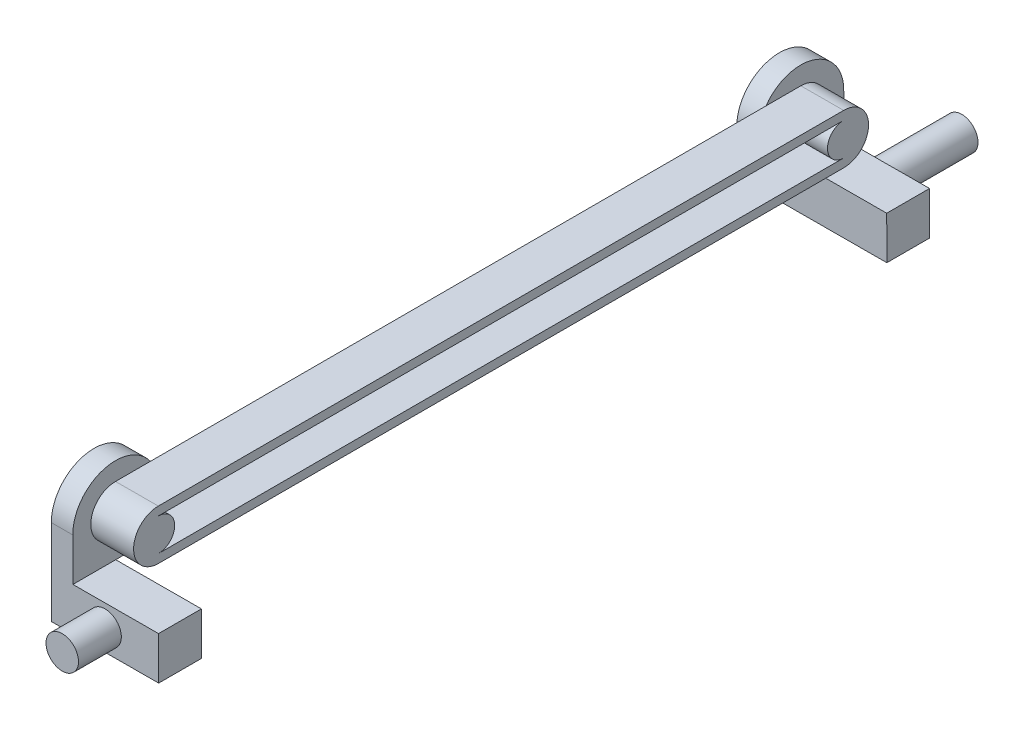
from build123d import *

# Parameters (mm, degrees)
SKETCH1_R           = 3.795
BOSS_EXTRUDE1_DEPTH = 10
BOSS_EXTRUDE2_DEPTH = 180
BOSS_EXTRUDE3_START = 10
SKETCH4_R           = 3.795
BOSS_EXTRUDE3_DEPTH = 10
SKETCH7_R           = 3.795
BOSS_EXTRUDE6_DEPTH = 5
SKETCH7_2_R         = 3.795
BOSS_EXTRUDE7_DEPTH = 15
BOSS_EXTRUDE8_DEPTH = 10
SKETCH9_W           = 479.703862309
SKETCH9_H           = 160
CUT_EXTRUDE1_DEPTH  = 420.035827381


with BuildPart() as part:
    # Sketch1 → Boss-Extrude1 (new, symmetric)
    with BuildSketch(Plane.XY):
        with Locations((354.729090947, 111.880692363)):
            Circle(SKETCH1_R)
    extrude(amount=BOSS_EXTRUDE1_DEPTH, both=True)

    # Sketch3 → Boss-Extrude2 (add)
    with BuildSketch(Plane.XY.offset(10)):
        Polygon((367.212888015, 116.921199692), (342.212888015, 116.840185034), (342.245293879, 106.840185034), (367.245293879, 106.921199692), align=None)
    extrude(amount=BOSS_EXTRUDE2_DEPTH)

    # Sketch4 → Boss-Extrude3 (add)
    with BuildSketch(Plane.XY.offset(190).offset(BOSS_EXTRUDE3_START)):
        with Locations((354.729090947, 111.880692363)):
            Circle(SKETCH4_R)
    extrude(amount=-BOSS_EXTRUDE3_DEPTH)

    # Sketch7 → Boss-Extrude6 (add)
    with BuildSketch(Plane(origin=(342.587921066, 1.110185725, 0), x_dir=(0, 0, 1), z_dir=(-0.9999947493415573, -0.0032405692888977803, 0))):
        with BuildLine():
            Line((10, 115.730606971), (10, 125.730606971))
            ThreePointArc((10, 125.730606971), (20, 135.730606971), (30, 125.730606971))
            Line((30, 125.730606971), (30, 115.730606971))
            Line((30, 115.730606971), (10, 115.730606971))
        make_face()
        with Locations((20, 125.730606971)):
            Circle(SKETCH7_R, mode=Mode.SUBTRACT)
    boss_extrude6 = extrude(amount=-BOSS_EXTRUDE6_DEPTH)

    # Sketch7_2 → Boss-Extrude7 (add)
    with BuildSketch(Plane(origin=(342.587921066, 1.110185725, 0), x_dir=(0, 0, 1), z_dir=(-0.9999947493415573, -0.0032405692888977803, 0))):
        with Locations((20, 125.730606971)):
            Circle(SKETCH7_2_R)
    boss_extrude7 = extrude(amount=-BOSS_EXTRUDE7_DEPTH)

    # Mirror2: Boss-Extrude6, Boss-Extrude7 across plane
    add(boss_extrude6.mirror(Plane.XY.offset(100)))
    add(boss_extrude7.mirror(Plane.XY.offset(100)))

    # Sketch8 → Boss-Extrude8 (add)
    with BuildSketch(Plane(origin=(347.587894813, 1.126388571, 0), x_dir=(0, 0, -1), z_dir=(0.9999947493415573, 0.003240569288897781, 0))):
        with BuildLine():
            Line((-180, 131.525606971), (-20, 131.525606971))
            ThreePointArc((-20, 131.525606971), (-14.205, 125.730606971), (-20, 119.935606971))
            Line((-20, 119.935606971), (-180, 119.935606971))
            ThreePointArc((-180, 119.935606971), (-185.795, 125.730606971), (-180, 131.525606971))
        make_face()
        with BuildLine():
            Line((-180, 129.525606971), (-20, 129.525606971))
            ThreePointArc((-20, 129.525606971), (-16.205, 125.730606971), (-20, 121.935606971))
            Line((-20, 121.935606971), (-180, 121.935606971))
            ThreePointArc((-180, 121.935606971), (-183.795, 125.730606971), (-180, 129.525606971))
        make_face(mode=Mode.SUBTRACT)
    extrude(amount=BOSS_EXTRUDE8_DEPTH)

    # Sketch9 → Cut-Extrude1 (cut, through all)
    with BuildSketch(Plane(origin=(-0.375033051, 115.729999309, 0), x_dir=(0.9999947493415573, 0.003240569288896666, 0), z_dir=(-0.003240569288896666, 0.9999947493415573, 0))):
        with Locations((127.73792, -100)):
            Rectangle(SKETCH9_W, SKETCH9_H)
    extrude(amount=-CUT_EXTRUDE1_DEPTH, mode=Mode.SUBTRACT)


solid = part.part
